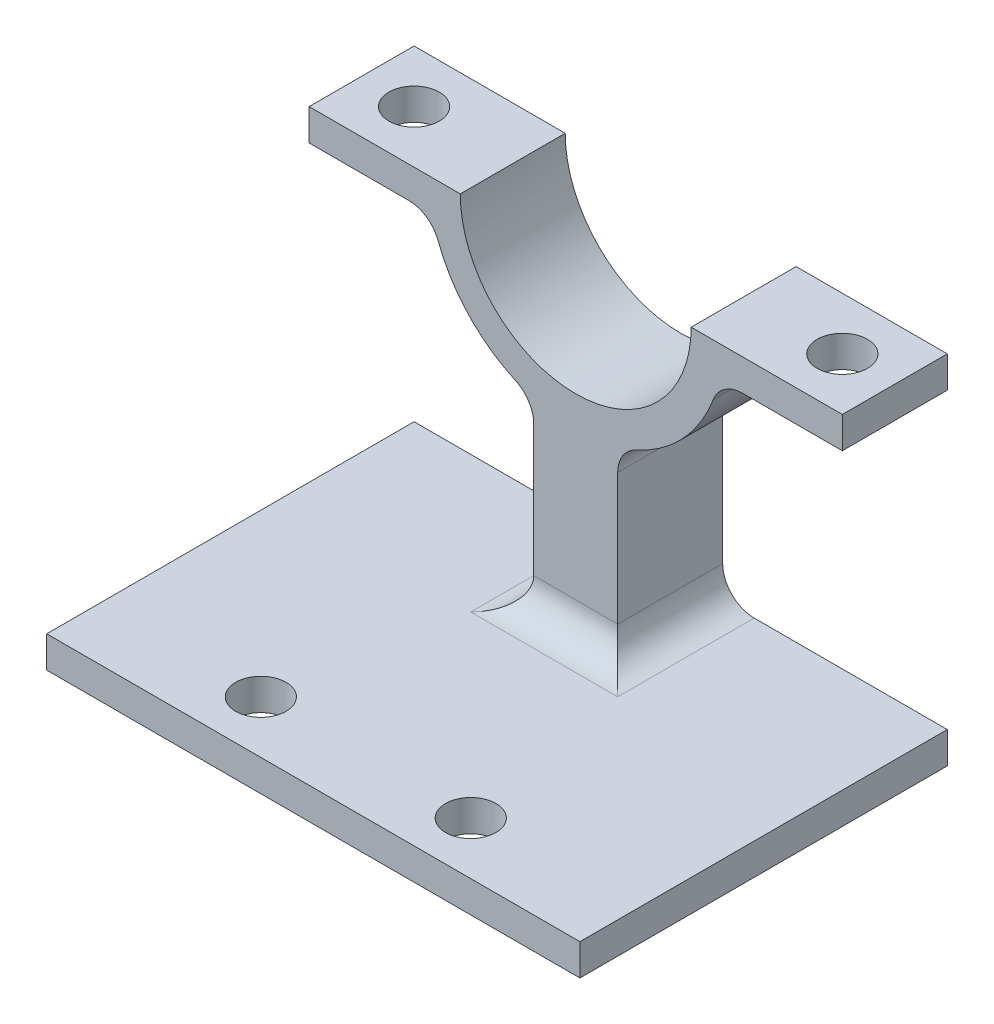
from build123d import *

# Parameters (mm, degrees)
BOSS_EXTRUDE1_DEPTH = 2.5
SKETCH2_R           = 1.2
CUT_EXTRUDE1_DEPTH  = 8
BOSS_EXTRUDE2_START = -15.5
SKETCH3_W           = 4
SKETCH3_H           = 5
BOSS_EXTRUDE2_DEPTH = 8.791796
SKETCH4_W           = 25.4
SKETCH4_H           = 17.5
BOSS_EXTRUDE3_DEPTH = 1.5
FILLET1_R           = 1.5
SKETCH5_R           = 1.2
CUT_EXTRUDE2_DEPTH  = 18


with BuildPart() as part:
    # Sketch1 → Boss-Extrude1 (new body, symmetric)
    with BuildSketch(Plane.XY):
        with BuildLine():
            Line((5.5, 0), (12.7, 0))
            Line((12.7, 0), (12.7, -1.5))
            Line((12.7, -1.5), (6.837397166, -1.5))
            ThreePointArc((6.837397166, -1.5), (0, -7), (-6.837397166, -1.5))
            Line((-6.837397166, -1.5), (-12.7, -1.5))
            Line((-12.7, -1.5), (-12.7, 0))
            Line((-12.7, 0), (-5.5, 0))
            ThreePointArc((-5.5, 0), (0, -5.5), (5.5, 0))
        make_face()
    extrude(amount=BOSS_EXTRUDE1_DEPTH, both=True)

    # Sketch2 → Cut-Extrude1 (cut, through all)
    with BuildSketch(Plane(origin=(0, 0, 0), x_dir=(1, 0, 0), z_dir=(0, 1, 0))):
        with Locations((-10.2, 0)):
            Circle(SKETCH2_R)
        with Locations((10.2, 0)):
            Circle(SKETCH2_R)
    extrude(amount=-CUT_EXTRUDE1_DEPTH, mode=Mode.SUBTRACT)

    # Sketch3 → Boss-Extrude2 (add)
    with BuildSketch(Plane(origin=(0, 0, 0), x_dir=(1, 0, 0), z_dir=(0, 1, 0)).offset(BOSS_EXTRUDE2_START)):
        Rectangle(SKETCH3_W, SKETCH3_H)
    extrude(amount=BOSS_EXTRUDE2_DEPTH)

    # Sketch4 → Boss-Extrude3 (add)
    with BuildSketch(Plane.XZ.offset(15.5)):
        with Locations((0, 6.25)):
            Rectangle(SKETCH4_W, SKETCH4_H)
    extrude(amount=BOSS_EXTRUDE3_DEPTH)

    # Fillet1
    fillet1_edges = [part.edges().sort_by_distance(p)[0] for p in [
        (6.837397166, -1.5, 0),
        (-6.837397166, -1.5, 0),
        (2, -15.5, 0),
        (-2, -15.5, 0),
        (0, -15.5, 2.5),
        (2, -6.708204, 0),
        (-2, -6.708204, 0),
    ]]
    fillet(fillet1_edges, radius=FILLET1_R)

    # Sketch5 → Cut-Extrude2 (cut, through all)
    with BuildSketch(Plane(origin=(0, 0, 0), x_dir=(1, 0, 0), z_dir=(0, 1, 0))):
        with Locations((-5, -12.5)):
            Circle(SKETCH5_R)
        with Locations((5, -12.5)):
            Circle(SKETCH5_R)
    extrude(amount=-CUT_EXTRUDE2_DEPTH, mode=Mode.SUBTRACT)


solid = part.part
